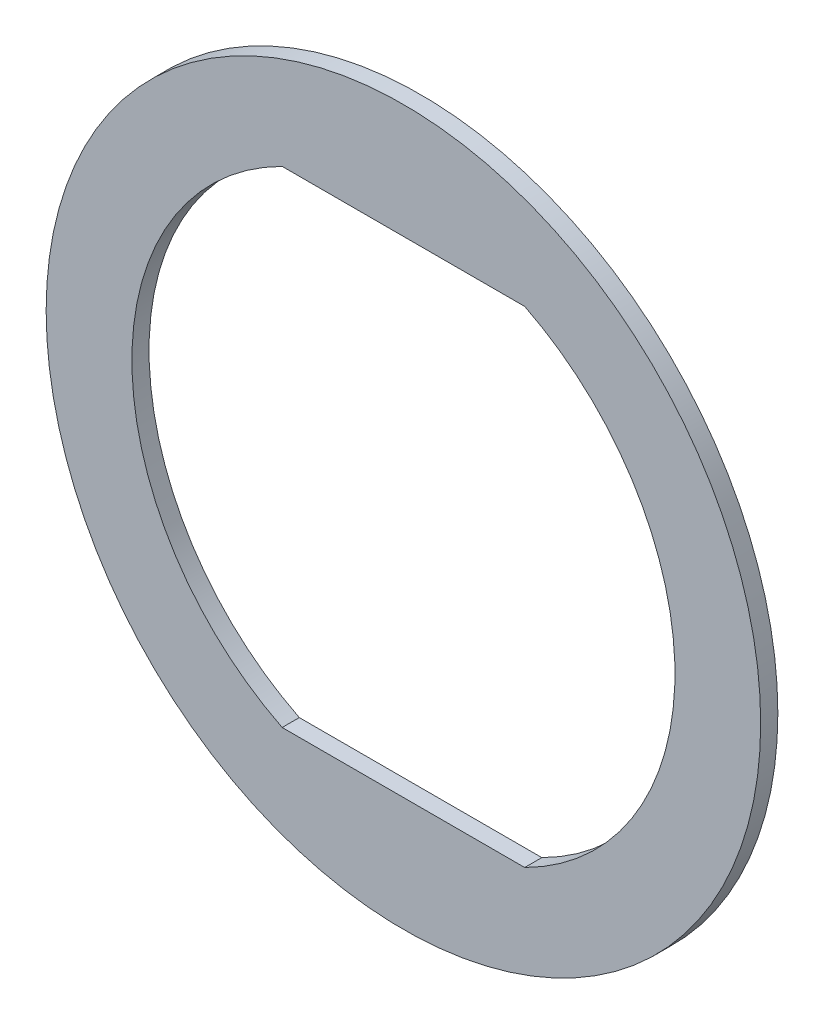
from build123d import *

# Parameters (mm, degrees)
SKIZZE1_R                       = 12.5
AUFSATZ_LINEAR_AUSTRAGEN1_DEPTH = 0.3


with BuildPart() as part:
    # Skizze1 → Aufsatz-Linear austragen1 (new body, symmetric)
    with BuildSketch(Plane.XY):
        Circle(SKIZZE1_R)
        with BuildLine():
            Line((-4.242640687, 8.5), (4.242640687, 8.5))
            ThreePointArc((4.242640687, 8.5), (9.5, 0), (4.242640687, -8.5))
            Line((4.242640687, -8.5), (-4.242640687, -8.5))
            ThreePointArc((-4.242640687, -8.5), (-9.5, 0), (-4.242640687, 8.5))
        make_face(mode=Mode.SUBTRACT)
    extrude(amount=AUFSATZ_LINEAR_AUSTRAGEN1_DEPTH, both=True)


solid = part.part
